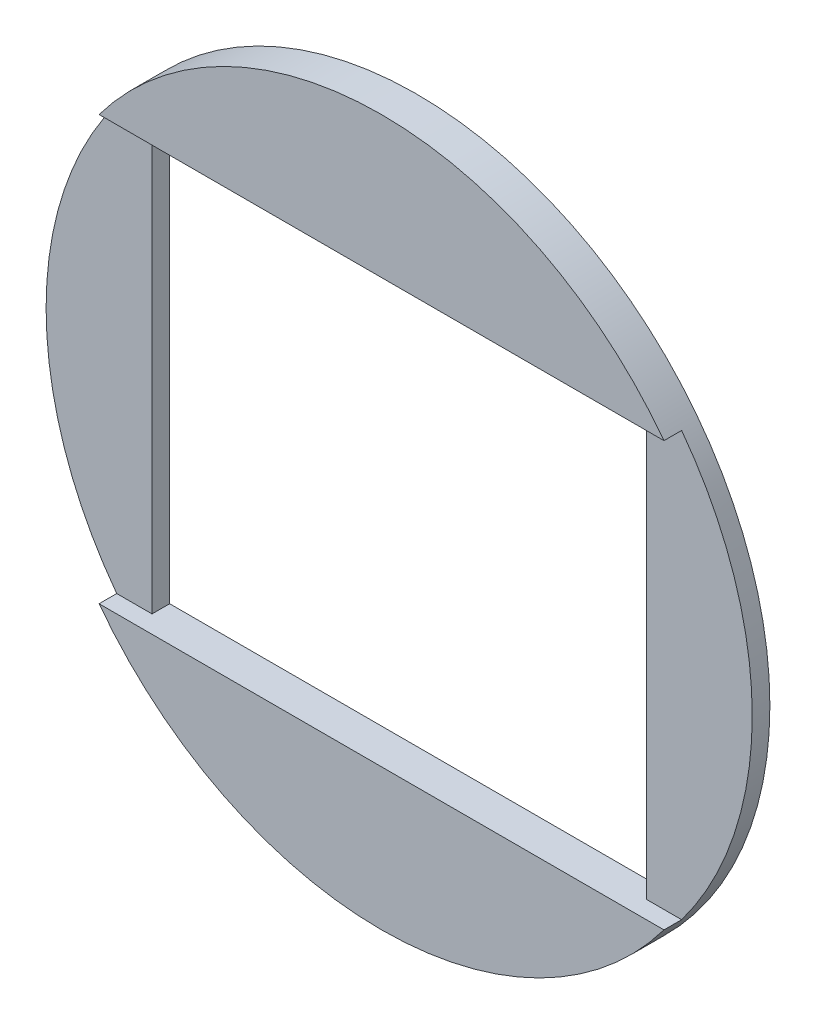
from build123d import *

# Parameters (mm, degrees)
SKETCH1_R                = 31.75
SKETCH1_W                = 44.45
SKETCH1_H                = 38.1
BASE_DEPTH               = 1.5875
TRENCH_REACH             = 11.525
SKETCH2_W                = 1.5875
SKETCH2_H                = 38.1
TRENCH_DIRECTION_2_REACH = 55.975


with BuildPart() as part:
    # Sketch1 → Base (new body, symmetric)
    with BuildSketch(Plane.XY):
        Circle(SKETCH1_R)
        Rectangle(SKETCH1_W, SKETCH1_H, mode=Mode.SUBTRACT)
    extrude(amount=BASE_DEPTH, both=True)

    # Sketch2 → Trench (cut, up to next)
    with BuildSketch(Plane.ZY.offset(-22.225), mode=Mode.PRIVATE) as trench_sk1:
        with Locations((0.79375, 0)):
            Rectangle(SKETCH2_W, SKETCH2_H)
    trench_tool1 = extrude(trench_sk1.sketch, amount=-TRENCH_REACH, mode=Mode.PRIVATE) & part.part
    add(trench_tool1.solids().sort_by_distance((22.225, 0, 0.79375))[0], mode=Mode.SUBTRACT)

    # Sketch2 → Trench direction 2 (cut, up to next)
    with BuildSketch(Plane.ZY.offset(-22.225), mode=Mode.PRIVATE) as trench_direction_2_sk1:
        with Locations((0.79375, 0)):
            Rectangle(SKETCH2_W, SKETCH2_H)
    trench_direction_2_tool1 = extrude(trench_direction_2_sk1.sketch, amount=TRENCH_DIRECTION_2_REACH, mode=Mode.PRIVATE) & part.part
    add(trench_direction_2_tool1.solids().sort_by_distance((22.225, 0, 0.79375))[0], mode=Mode.SUBTRACT)


solid = part.part
